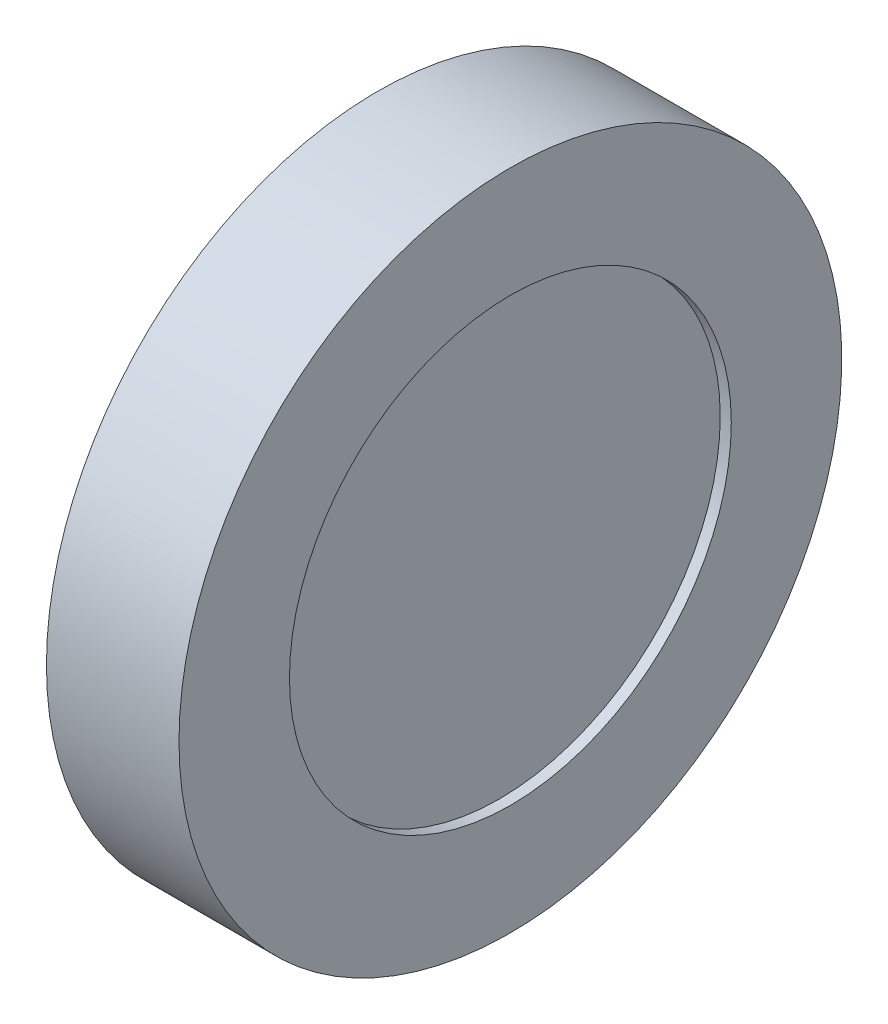
from build123d import *

# Parameters (mm, degrees)
SKETCH_1_W = 5
SKETCH_1_H = 10
SKETCH_4_W = 6
SKETCH_4_H = 5


with BuildPart() as part:
    # 草图1 → 旋转2 (revolve)
    with BuildSketch(Plane.XY, mode=Mode.PRIVATE) as revolve_2_sk:
        with Locations((0, 5)):
            Rectangle(SKETCH_1_W, SKETCH_1_H)
    revolve(revolve_2_sk.sketch.rotate(Axis((-2.5, 0, 0), (1, 0, 0)), 90), axis=Axis((-2.5, 0, 0), (1, 0, 0)))  # turned: the seam where the file's is

    # 草图4 → 旋转3 (revolve)
    with BuildSketch(Plane.XY, mode=Mode.PRIVATE) as revolve_3_sk:
        with Locations((0, 12.5)):
            Rectangle(SKETCH_4_W, SKETCH_4_H)
    revolve(revolve_3_sk.sketch.rotate(Axis((-1.614212419, 0, 0), (1, 0, 0)), 90), axis=Axis((-1.614212419, 0, 0), (1, 0, 0)))  # turned: the seam where the file's is


solid = part.part
